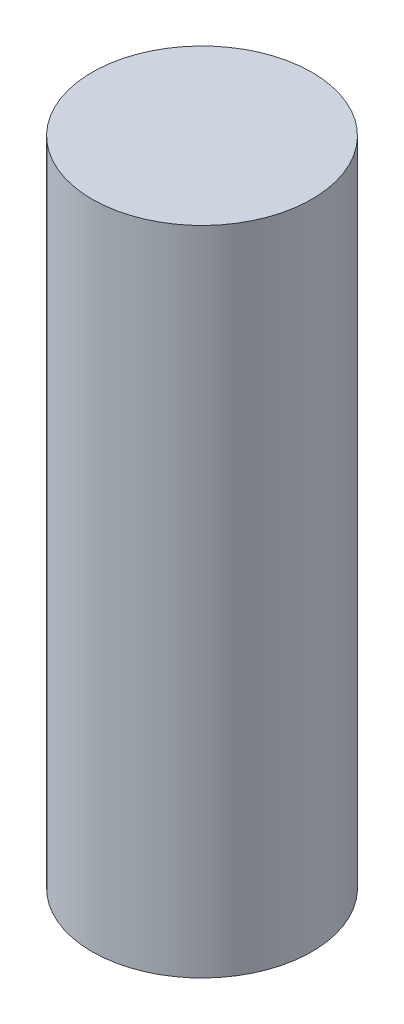
from build123d import *

# Parameters (mm, degrees)
SKETCH1_R           = 7
BOSS_EXTRUDE1_DEPTH = 20.75


with BuildPart() as part:
    # Sketch1 → Boss-Extrude1 (new body, symmetric)
    with BuildSketch(Plane(origin=(0, 0, 0), x_dir=(1, 0, 0), z_dir=(0, 1, 0))):
        Circle(SKETCH1_R)
    extrude(amount=BOSS_EXTRUDE1_DEPTH, both=True)


solid = part.part
